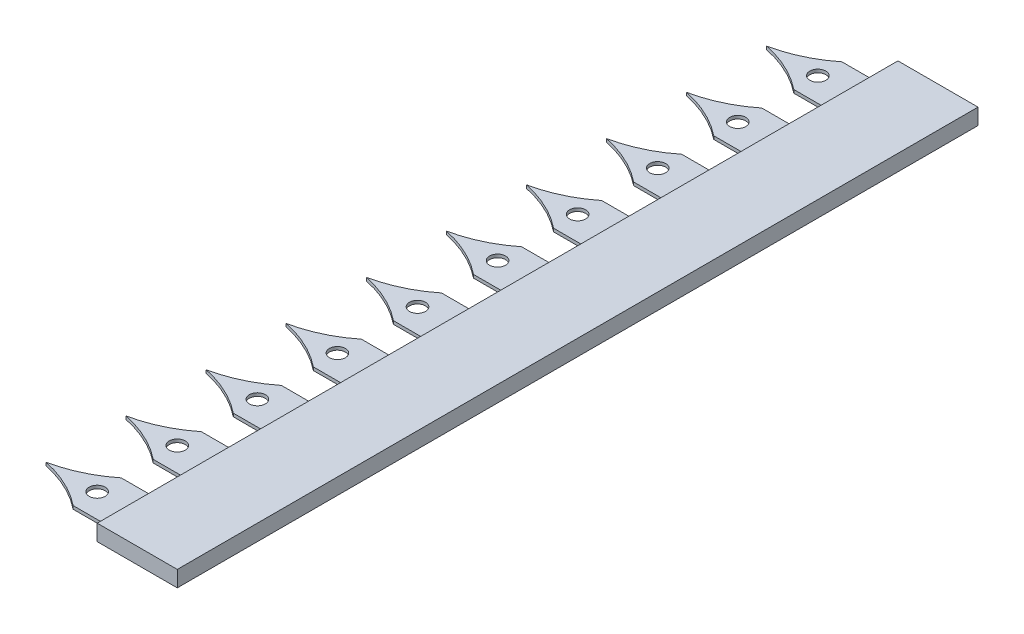
from build123d import *

# Parameters (mm, degrees)
SKETCH1_W           = 50
SKETCH1_H           = 10
BOSS_EXTRUDE1_DEPTH = 50
SKETCH2_R           = 5
BOSS_EXTRUDE2_DEPTH = 2
LPATTERN1_COUNT     = 10
LPATTERN1_PITCH     = 50


with BuildPart() as part:
    # Sketch1 → Boss-Extrude1 (new body)
    with BuildSketch(Plane.XY):
        Rectangle(SKETCH1_W, SKETCH1_H)
    boss_extrude1 = extrude(amount=BOSS_EXTRUDE1_DEPTH)

    # Sketch2 → Boss-Extrude2 (add)
    with BuildSketch(Plane.XZ.offset(5)):
        with BuildLine():
            Line((-50, 10), (-25, 10))
            Line((-25, 10), (-25, 40))
            Line((-25, 40), (-50, 40))
            add(Edge.make_bspline(
                [(-50, 40), (-64.127186128, 28.759951739), (-81.969053702, 25)],
                knots=[0, 0, 0, 1, 1, 1], degree=2))
            add(Edge.make_bspline(
                [(-50, 10), (-64.127186128, 21.240048261), (-81.969053702, 25)],
                knots=[0, 0, 0, 1, 1, 1], degree=2))
        make_face()
        with Locations((-50, 25)):
            Circle(SKETCH2_R, mode=Mode.SUBTRACT)
    boss_extrude2 = extrude(amount=-BOSS_EXTRUDE2_DEPTH)

    # LPattern1: Boss-Extrude1, Boss-Extrude2 ×10
    with Locations(*[(0, 0, i * LPATTERN1_PITCH) for i in range(1, LPATTERN1_COUNT)]):
        add(boss_extrude1)
        add(boss_extrude2)


solid = part.part
